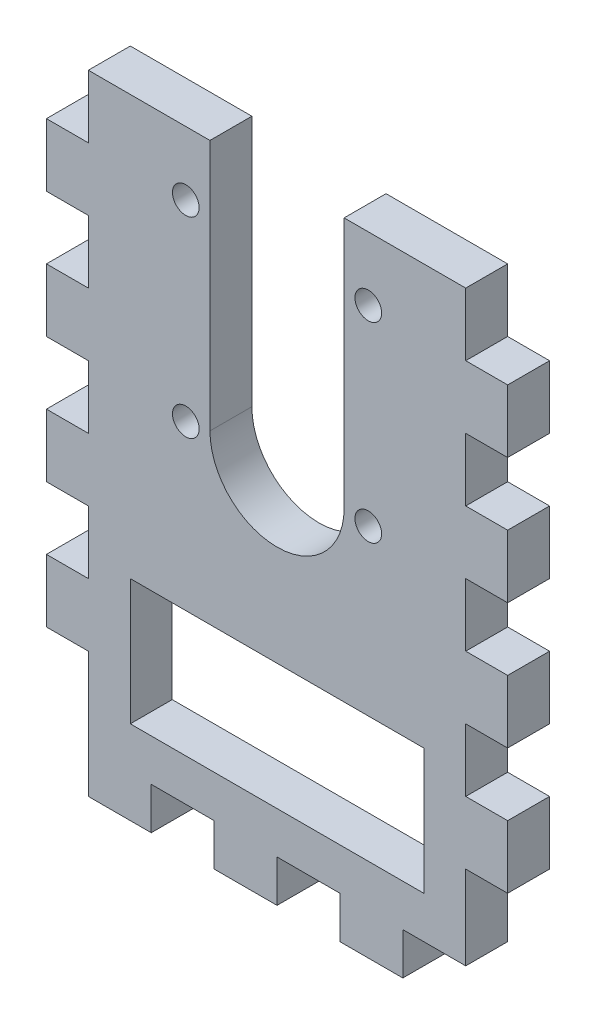
from build123d import *

# Parameters (mm, degrees)
SKETCH1_W           = 57.15
SKETCH1_H           = 88.9
BOSS_EXTRUDE1_DEPTH = 6.35
SKETCH2_R           = 2.0193
SKETCH2_W           = 44.45
SKETCH2_H           = 19.05
CUT_EXTRUDE1_DEPTH  = 6.35
SKETCH3_W           = 6.35
SKETCH3_H           = 9.525
SKETCH3_W_2         = 9.525
SKETCH3_H_2         = 6.35
BOSS_EXTRUDE3_DEPTH = 6.35


with BuildPart() as part:
    # Sketch1 → Boss-Extrude1 (new body)
    with BuildSketch(Plane.XY):
        with Locations((28.575, -44.45)):
            Rectangle(SKETCH1_W, SKETCH1_H)
    extrude(amount=BOSS_EXTRUDE1_DEPTH)

    # Sketch2 → Cut-Extrude1 (cut)
    with BuildSketch(Plane.XY.offset(6.35)):
        with Locations((42.3926, -9.652)):
            Circle(SKETCH2_R)
        with Locations((42.3926, -38.608)):
            Circle(SKETCH2_R)
        with Locations((14.7574, -38.6842)):
            Circle(SKETCH2_R)
        with Locations((14.7574, -9.652)):
            Circle(SKETCH2_R)
        with BuildLine():
            Line((38.735, 0), (38.735, -38.1))
            ThreePointArc((38.735, -38.1), (28.575, -48.26), (18.415, -38.1))
            Line((18.415, -38.1), (18.415, 0))
            ThreePointArc((18.415, 0), (28.575, 10.16), (38.735, 0))
        make_face()
        with Locations((28.575, -73.025)):
            Rectangle(SKETCH2_W, SKETCH2_H)
    extrude(amount=-CUT_EXTRUDE1_DEPTH, mode=Mode.SUBTRACT)

    # Sketch3 → Boss-Extrude3 (add)
    with BuildSketch(Plane.XY):
        with Locations((-3.175, -14.2875)):
            Rectangle(SKETCH3_W, SKETCH3_H)
        with Locations((-3.175, -33.3375)):
            Rectangle(SKETCH3_W, SKETCH3_H)
        with Locations((-3.175, -52.3875)):
            Rectangle(SKETCH3_W, SKETCH3_H)
        with Locations((-3.175, -71.4375)):
            Rectangle(SKETCH3_W, SKETCH3_H)
        with Locations((4.7625, -92.075)):
            Rectangle(SKETCH3_W_2, SKETCH3_H_2)
        with Locations((60.325, -71.4375)):
            Rectangle(SKETCH3_W, SKETCH3_H)
        with Locations((60.325, -52.3875)):
            Rectangle(SKETCH3_W, SKETCH3_H)
        with Locations((60.325, -33.3375)):
            Rectangle(SKETCH3_W, SKETCH3_H)
        with Locations((60.325, -14.2875)):
            Rectangle(SKETCH3_W, SKETCH3_H)
        with Locations((23.8125, -92.075)):
            Rectangle(SKETCH3_W_2, SKETCH3_H_2)
        with Locations((42.8625, -92.075)):
            Rectangle(SKETCH3_W_2, SKETCH3_H_2)
    extrude(amount=BOSS_EXTRUDE3_DEPTH)


solid = part.part
